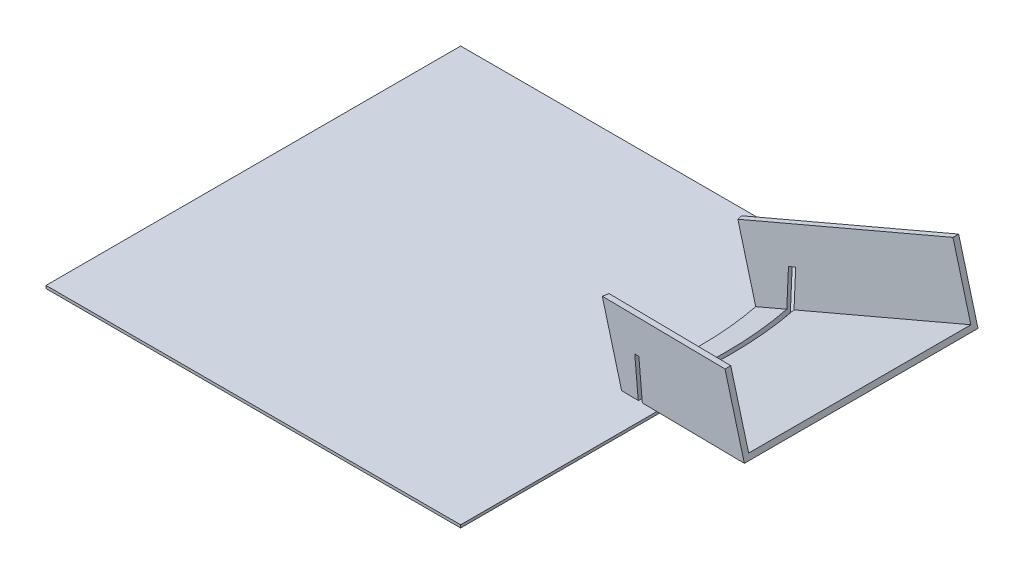
from build123d import *

# Parameters (mm, degrees)
SKETCH4_W           = 150
SKETCH4_H           = 150
BOSS_EXTRUDE4_DEPTH = 1
BOSS_EXTRUDE5_DEPTH = 2
BOSS_EXTRUDE6_START = 2
BOSS_EXTRUDE6_DEPTH = 25
SKETCH8_R           = 101.1
SKETCH8_R_2         = 98.9
CUT_EXTRUDE4_DEPTH  = 15


with BuildPart() as part:
    # Sketch4 → Boss-Extrude4 (new body)
    with BuildSketch(Plane(origin=(0, 0, 0), x_dir=(1, 0, 0), z_dir=(0, 1, 0))):
        Rectangle(SKETCH4_W, SKETCH4_H)
    extrude(amount=BOSS_EXTRUDE4_DEPTH)


with BuildPart() as body_2:
    # Sketch1 → Boss-Extrude5 (new body)
    with BuildSketch(Plane(origin=(0, 0, 0), x_dir=(0.9659258262890681, 0.25881904510252135, 0), z_dir=(-0.25881904510252135, 0.9659258262890681, 0))):
        with BuildLine():
            ThreePointArc((86.394218607, 25.219813467), (90, 0), (86.394218607, -25.219813467))
            Line((86.394218607, -25.219813467), (150, -42.262931225))
            Line((150, -42.262931225), (150, 42.262931225))
            Line((150, 42.262931225), (86.394218607, 25.219813467))
        make_face()
    extrude(amount=BOSS_EXTRUDE5_DEPTH)

    # Sketch1_7 → Boss-Extrude6 (add)
    with BuildSketch(Plane(origin=(0, 0, 0), x_dir=(0.9659258262890681, 0.25881904510252135, 0), z_dir=(-0.25881904510252135, 0.9659258262890681, 0)).offset(BOSS_EXTRUDE6_START)):
        with BuildLine():
            ThreePointArc((86.394218607, 25.219813467), (86.669122258, 24.258261418), (86.933324366, 23.293714059))
            Line((86.933324366, 23.293714059), (150, 40.192378865))
            Line((150, 40.192378865), (150, 42.262931225))
            Line((150, 42.262931225), (86.394218607, 25.219813467))
        make_face()
        with BuildLine():
            ThreePointArc((86.933324366, -23.293714059), (86.669122258, -24.258261418), (86.394218607, -25.219813467))
            Line((86.394218607, -25.219813467), (150, -42.262931225))
            Line((150, -42.262931225), (150, -40.192378865))
            Line((150, -40.192378865), (86.933324366, -23.293714059))
        make_face()
    extrude(amount=BOSS_EXTRUDE6_DEPTH)

    # Sketch8 → Cut-Extrude4 (cut, along a direction that is not the sketch's normal)
    with BuildSketch(Plane(origin=(0, 0, 0), x_dir=(-0.9659258262890681, -0.25881904510252135, 0), z_dir=(0.25881904510252135, -0.9659258262890681, 0))):
        Circle(SKETCH8_R)
        Circle(SKETCH8_R_2, mode=Mode.SUBTRACT)
    extrude(amount=-CUT_EXTRUDE4_DEPTH, dir=(0, -1, 0), mode=Mode.SUBTRACT)


solid = Compound([part.part, body_2.part])
